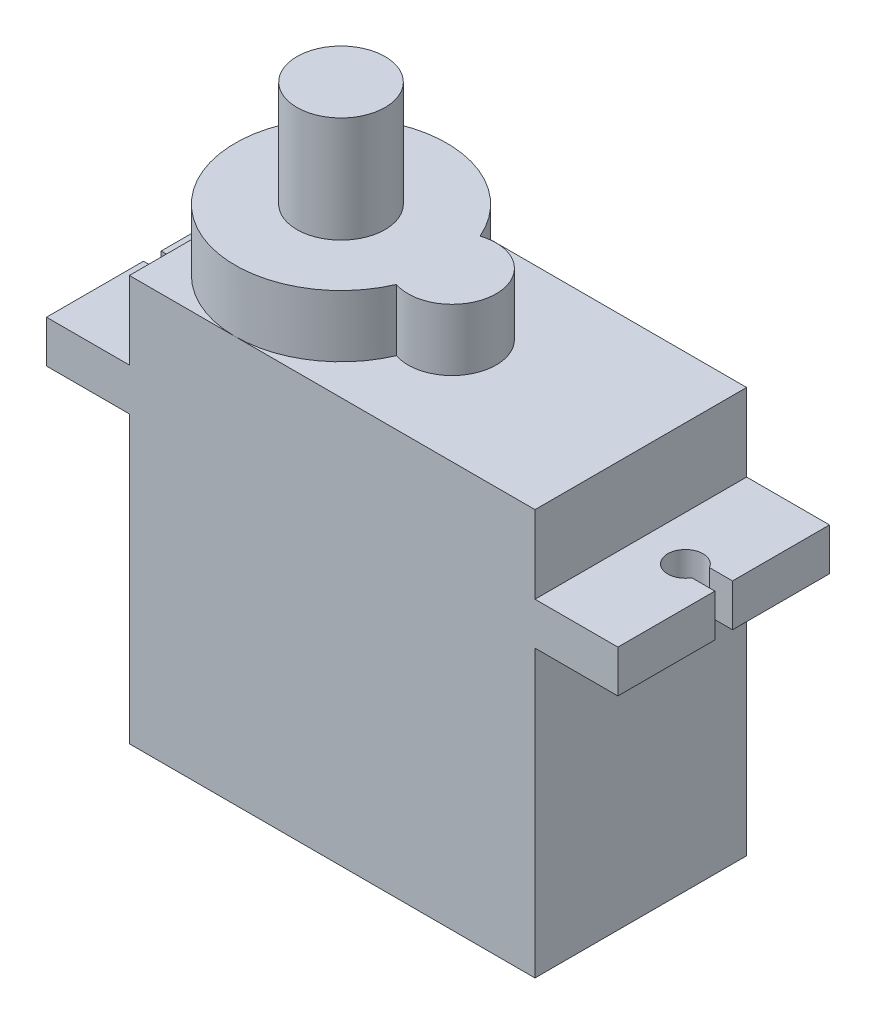
from build123d import *

# Parameters (mm, degrees)
SKETCH2_W           = 23
SKETCH2_H           = 12
BOSS_EXTRUDE1_DEPTH = 23
BOSS_EXTRUDE2_START = -4.4
BOSS_EXTRUDE2_DEPTH = 2.4
SKETCH4_R           = 6
SKETCH4_R_2         = 2.5
BOSS_EXTRUDE3_DEPTH = 3.5
BOSS_EXTRUDE4_DEPTH = 3
SKETCH6_W           = 3
SKETCH6_H           = 1
BOSS_EXTRUDE5_DEPTH = 3
SKETCH7_R           = 2.5
BOSS_EXTRUDE6_DEPTH = 3


with BuildPart() as part:
    # Sketch2 → Boss-Extrude1 (new body)
    with BuildSketch(Plane(origin=(0, 0, 0), x_dir=(1, 0, 0), z_dir=(0, 1, 0))):
        Rectangle(SKETCH2_W, SKETCH2_H)
    extrude(amount=-BOSS_EXTRUDE1_DEPTH)

    # Sketch3 → Boss-Extrude2 (add)
    with BuildSketch(Plane(origin=(0, 0, 0), x_dir=(1, 0, 0), z_dir=(0, 1, 0)).offset(BOSS_EXTRUDE2_START)):
        with BuildLine():
            Line((-16.2, -0.5), (-16.2, -6))
            Line((-16.2, -6), (-11.5, -6))
            Line((-11.5, -6), (-11.5, 6))
            Line((-11.5, 6), (-16.2, 6))
            Line((-16.2, 6), (-16.2, 0.5))
            Line((-16.2, 0.5), (-15.584293743, 0.5))
            ThreePointArc((-15.584293743, 0.5), (-14.459449294, 0.965925826), (-13.718268339, 0))
            ThreePointArc((-13.718268339, 0), (-14.459449294, -0.965925826), (-15.584293743, -0.5))
            Line((-15.584293743, -0.5), (-16.2, -0.5))
        make_face()
        with BuildLine():
            Line((11.5, 6), (11.5, -6))
            Line((11.5, -6), (16.2, -6))
            Line((16.2, -6), (16.2, -0.5))
            Line((16.2, -0.5), (14.894380034, -0.5))
            ThreePointArc((14.894380034, -0.5), (13.02835463, 0), (14.894380034, 0.5))
            Line((14.894380034, 0.5), (16.2, 0.5))
            Line((16.2, 0.5), (16.2, 6))
            Line((16.2, 6), (11.5, 6))
        make_face()
    extrude(amount=-BOSS_EXTRUDE2_DEPTH)

    # Sketch4 → Boss-Extrude3 (add)
    with BuildSketch(Plane(origin=(0, 0, 0), x_dir=(1, 0, 0), z_dir=(0, 1, 0))):
        with Locations((-5.5, 0)):
            Circle(SKETCH4_R)
        with Locations((0.8, 0)):
            Circle(SKETCH4_R_2)
    extrude(amount=BOSS_EXTRUDE3_DEPTH)

    # Sketch5 → Boss-Extrude4 (add)
    with BuildSketch(Plane(origin=(0, 3.5, 0), x_dir=(1, 0, 0), z_dir=(0, 1, 0))):
        Polygon((-3.255005568, -0.15), (-3.437184296, 0), (-3.255005568, 0.15), (-3.455589794, 0.274946425), (-3.295142762, 0.44844683), (-3.51047784, 0.544986424), (-3.374587739, 0.738324266), (-3.600868956, 0.805301127), (-3.491960749, 1.015026288), (-3.725150111, 1.051245213), (-3.645167266, 1.273615142), (-3.881103504, 1.278429803), (-3.831473318, 1.509476304), (-4.065946143, 1.482800783), (-4.047554268, 1.718400825), (-4.276379508, 1.660711148), (-4.289554146, 1.896660443), (-4.508648409, 1.808986083), (-4.553154459, 2.04107411), (-4.758608002, 1.924979619), (-4.833651254, 2.149064761), (-5.021797754, 2.006621847), (-5.126039057, 2.218705301), (-5.293521035, 2.052455862), (-5.425100203, 2.248752992), (-5.568928939, 2.061663752), (-5.725497937, 2.238671633), (-5.843106805, 2.034081205), (-6.021871655, 2.188641125), (-6.111161921, 1.97020043), (-6.308932561, 2.099554265), (-6.368310838, 1.871161381), (-6.581558046, 1.973000809), (-6.609964728, 1.738731414), (-6.834883102, 1.811239107), (-6.831811271, 1.575273743), (-7.064387138, 1.6171558), (-7.02989161, 1.383705275), (-7.265974648, 1.39421431), (-7.200670997, 1.167444554), (-7.436048299, 1.146393032), (-7.34110187, 0.930350756), (-7.571573122, 0.878114343), (-7.448678237, 0.676654828), (-7.670130674, 0.594165683), (-7.521480394, 0.410883978), (-7.729962192, 0.299614123), (-7.558209186, 0.137780894), (-7.749999982, -0.000284059), (-7.558209186, -0.137780894), (-7.729886469, -0.300177172), (-7.521480394, -0.410883978), (-7.669980579, -0.594713616), (-7.448678237, -0.676654828), (-7.571351335, -0.878637381), (-7.34110187, -0.930350756), (-7.435758777, -1.146881842), (-7.200670997, -1.167444554), (-7.265622557, -1.394660168), (-7.02989161, -1.383705275), (-7.063978761, -1.617550752), (-6.831811271, -1.575273743), (-6.834425728, -1.811576103), (-6.609964728, -1.738731414), (-6.581059835, -1.973273836), (-6.368310838, -1.871161381), (-6.308402404, -2.099758451), (-6.111161921, -1.97020043), (-6.021319013, -2.188772827), (-5.843106805, -2.034081205), (-5.724932672, -2.238728499), (-5.568928939, -2.061663752), (-5.424532402, -2.248734009), (-5.293521035, -2.052455862), (-5.125478853, -2.218610806), (-5.021797754, -2.006621847), (-4.833108643, -2.148896442), (-4.758608002, -1.924979619), (-4.552639125, -2.040834969), (-4.508648409, -1.808986083), (-4.289075284, -1.896354748), (-4.276379508, -1.660711148), (-4.047120423, -1.718034032), (-4.065946143, -1.482800783), (-3.831092233, -1.509054958), (-3.881103504, -1.278429803), (-3.644845742, -1.273146762), (-3.725150111, -1.051245213), (-3.491704522, -1.014519232), (-3.600868956, -0.805301127), (-3.374401382, -0.737787582), (-3.51047784, -0.544986424), (-3.295029601, -0.447890096), (-3.455589794, -0.274946425), align=None)
    extrude(amount=BOSS_EXTRUDE4_DEPTH)

    # Sketch6 → Boss-Extrude5 (add)
    with BuildSketch(Plane.ZY.offset(11.5)):
        with Locations((0, -17.5)):
            Rectangle(SKETCH6_W, SKETCH6_H)
    extrude(amount=BOSS_EXTRUDE5_DEPTH)

    # Sketch7 → Boss-Extrude6 (add, symmetric)
    with BuildSketch(Plane(origin=(0, 6.5, 0), x_dir=(1, 0, 0), z_dir=(0, 1, 0))):
        with Locations((-5.5, 0)):
            Circle(SKETCH7_R)
    extrude(amount=BOSS_EXTRUDE6_DEPTH, both=True)


solid = part.part
